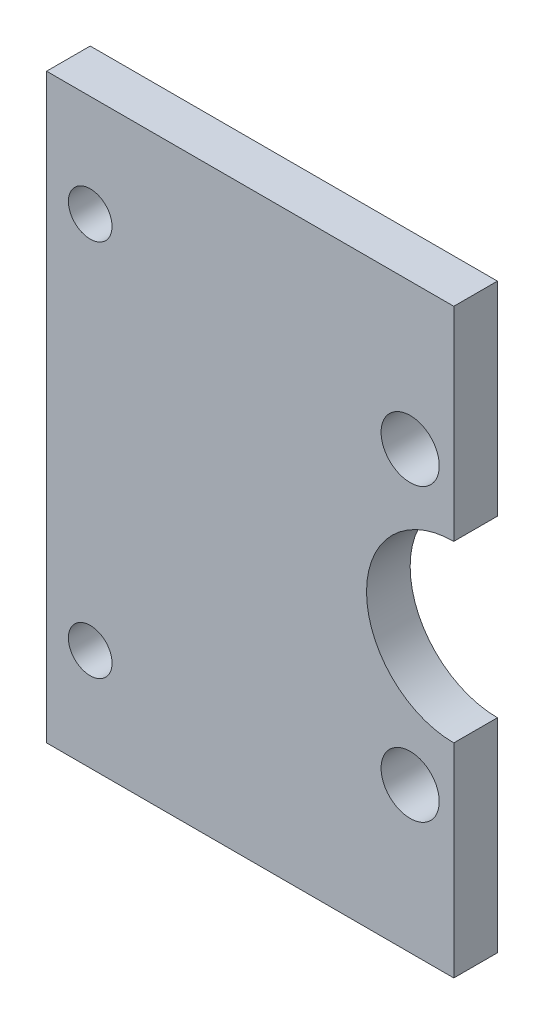
from build123d import *

# Parameters (mm, degrees)
ESQUISSE1_W             = 28
ESQUISSE1_H             = 40
BOSS_EXTRU_1_DEPTH      = 3
ESQUISSE7_R             = 1.5
ENL_V_MAT_EXTRU_6_DEPTH = 5
ESQUISSE8_R             = 2
ENL_V_MAT_EXTRU_7_DEPTH = 10
ESQUISSE9_R             = 6
ENL_V_MAT_EXTRU_8_DEPTH = 10


with BuildPart() as part:
    # Esquisse1 → Boss.-Extru.1 (new body)
    with BuildSketch(Plane.XY):
        Rectangle(ESQUISSE1_W, ESQUISSE1_H)
    extrude(amount=BOSS_EXTRU_1_DEPTH)

    # Esquisse7 → Enlèv. mat.-Extru.6 (cut)
    with BuildSketch(Plane.XY.offset(3)):
        with Locations((-11, 13)):
            Circle(ESQUISSE7_R)
    enl_v_mat_extru_6 = extrude(amount=-ENL_V_MAT_EXTRU_6_DEPTH, mode=Mode.SUBTRACT)

    # Symétrie2: Enlèv. mat.-Extru.6 across plane
    add(enl_v_mat_extru_6.mirror(Plane.ZX), mode=Mode.SUBTRACT)

    # Esquisse8 → Enlèv. mat.-Extru.7 (cut)
    with BuildSketch(Plane.XY.offset(3)):
        with Locations((11, 10)):
            Circle(ESQUISSE8_R)
    enl_v_mat_extru_7 = extrude(amount=-ENL_V_MAT_EXTRU_7_DEPTH, mode=Mode.SUBTRACT)

    # Symétrie3: Enlèv. mat.-Extru.7 across plane
    add(enl_v_mat_extru_7.mirror(Plane.ZX), mode=Mode.SUBTRACT)

    # Esquisse9 → Enlèv. mat.-Extru.8 (cut)
    with BuildSketch(Plane.XY.offset(3)):
        with Locations((14, 0)):
            Circle(ESQUISSE9_R)
    extrude(amount=-ENL_V_MAT_EXTRU_8_DEPTH, mode=Mode.SUBTRACT)


solid = part.part
